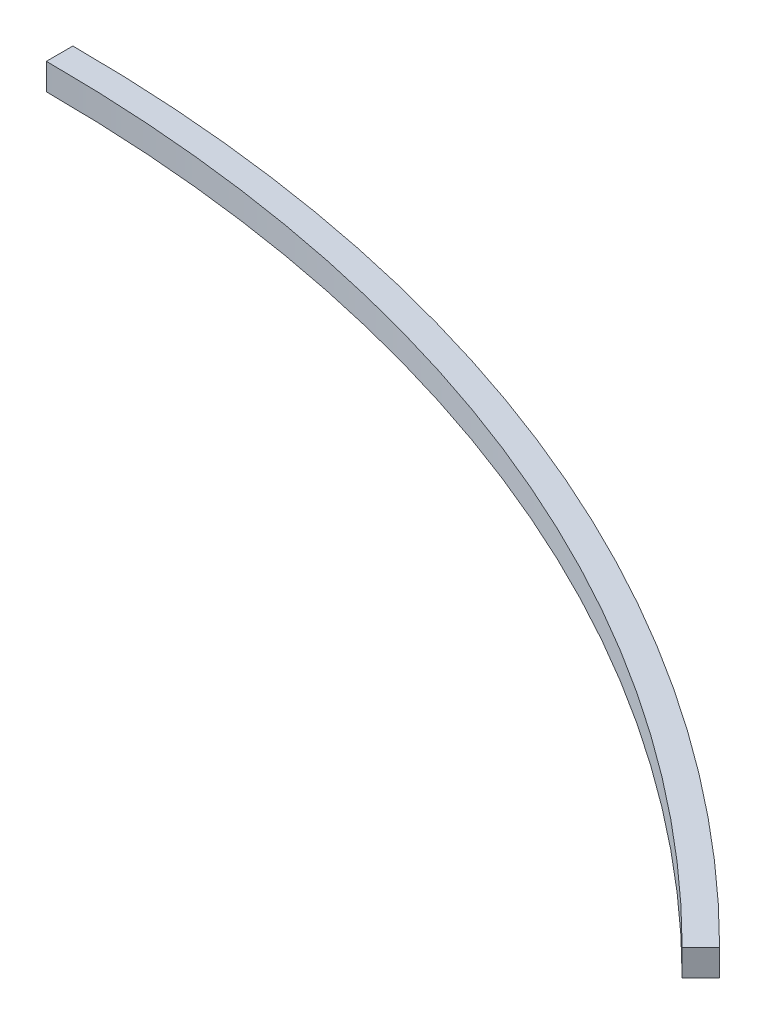
from build123d import *

# Parameters (mm, degrees)
BOSS_EXTRUDE1_DEPTH = 10


with BuildPart() as part:
    # Sketch1 → Boss-Extrude1 (new body)
    with BuildSketch(Plane(origin=(0, 0, 0), x_dir=(1, 0, 0), z_dir=(0, 1, 0))):
        with BuildLine():
            ThreePointArc((0, 590), (225.783225095, 545.088924182), (417.1930009, 417.1930009))
            Line((417.1930009, 417.1930009), (410.121933088, 410.121933088))
            ThreePointArc((410.121933088, 410.121933088), (221.956390772, 535.850128857), (0, 580))
            Line((0, 580), (0, 590))
        make_face()
    extrude(amount=BOSS_EXTRUDE1_DEPTH)


solid = part.part
